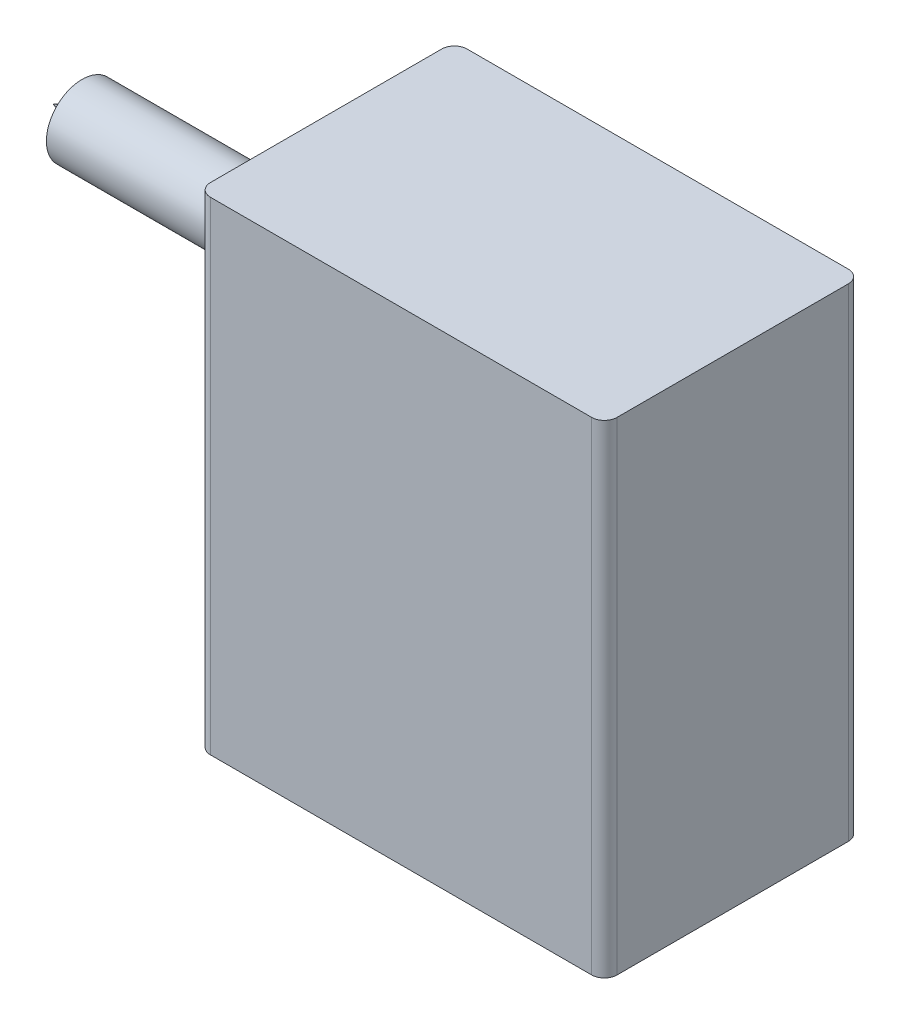
from build123d import *

# Parameters (mm, degrees)
SZKIC1_W                    = 320
SZKIC1_H                    = 380
DODANIE_WYCI_GNI_CIE1_DEPTH = 202
SZKIC2_R                    = 75.8204014
DODANIE_WYCI_GNI_CIE2_DEPTH = 16
SZKIC3_R                    = 28.051161272
DODANIE_WYCI_GNI_CIE3_DEPTH = 176
ZAOKR_GLENIE1_R             = 10


with BuildPart() as part:
    # Szkic1 → Dodanie-wyciągnięcie1 (new body)
    with BuildSketch(Plane.XY):
        with Locations((180.509851846, 381.331636977)):
            Rectangle(SZKIC1_W, SZKIC1_H)
    extrude(amount=DODANIE_WYCI_GNI_CIE1_DEPTH)

    # Szkic2 → Dodanie-wyciągnięcie2 (add)
    with BuildSketch(Plane.ZY.offset(-20.509851846)):
        with Locations(Location((101, 472.09116861, 0), (0, 0, 270))):
            Circle(SZKIC2_R)
    extrude(amount=DODANIE_WYCI_GNI_CIE2_DEPTH)

    # Szkic3 → Dodanie-wyciągnięcie3 (add)
    with BuildSketch(Plane.ZY.offset(-4.509851846)):
        with Locations(Location((101, 472.09116861, 0), (0, 0, 270))):
            Circle(SZKIC3_R)
    extrude(amount=DODANIE_WYCI_GNI_CIE3_DEPTH)

    # Dodanie-wyciągnięcie4 cone 1 section (through the dimple's axis) → Dodanie-wyciągnięcie4 (revolve)
    with BuildSketch(Plane(origin=(-171.490148154, 472.09116861, 101), x_dir=(0, 0, -1), z_dir=(0, 1, 0))):
        Polygon((0, 0), (8.316206597, 0), (0, 22.848589841), align=None)
    revolve(axis=Axis((-171.490148154, 472.09116861, 101), (-1, 0, 0)))

    # Zaokrąglenie1
    zaokr_glenie1_edges = [part.edges().sort_by_distance(p)[0] for p in [
        (20.509851846, 381.331636977, 202),
        (340.509851846, 381.331636977, 202),
        (20.509851846, 381.331636977, 0),
        (340.509851846, 381.331636977, 0),
    ]]
    fillet(zaokr_glenie1_edges, radius=ZAOKR_GLENIE1_R)


solid = part.part
